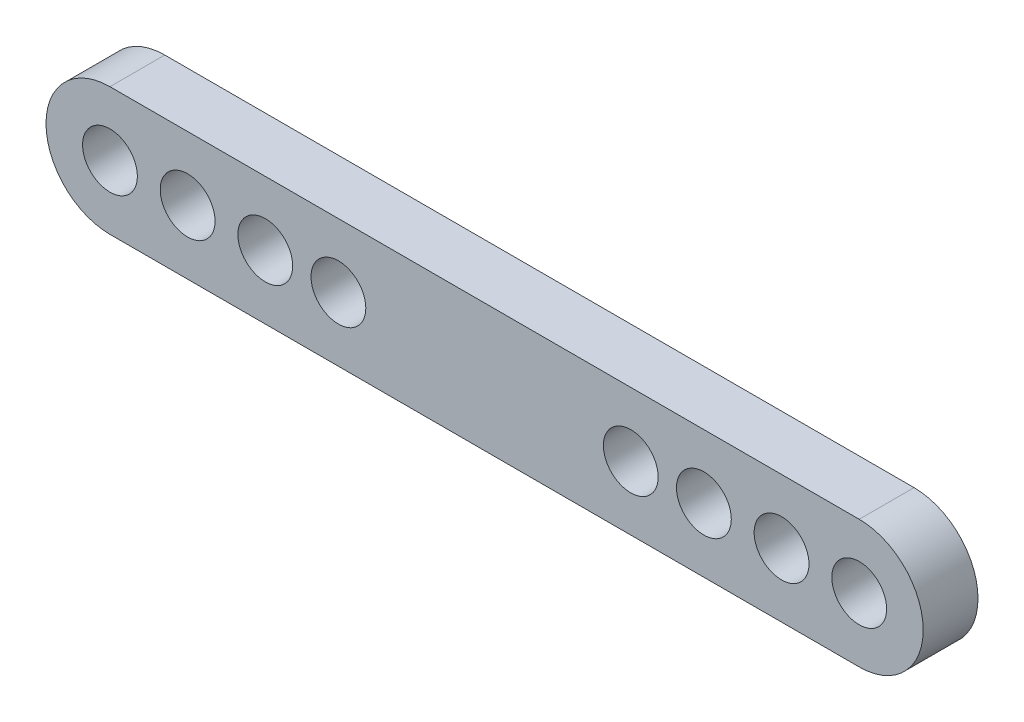
from build123d import *

# Parameters (mm, degrees)
SKETCH_1_R      = 1.5
EXTRUDE_1_DEPTH = 3


with BuildPart() as part:
    # 草图1 → 凸台-拉伸1 (new body)
    with BuildSketch(Plane.XY):
        with BuildLine():
            Line((-20.5, 3.5), (20.5, 3.5))
            ThreePointArc((20.5, 3.5), (24, 0), (20.5, -3.5))
            Line((20.5, -3.5), (-20.5, -3.5))
            ThreePointArc((-20.5, -3.5), (-24, 0), (-20.5, 3.5))
        make_face()
        with Locations((-20.5, 0)):
            Circle(SKETCH_1_R, mode=Mode.SUBTRACT)
        with Locations((-16.25, 0)):
            Circle(SKETCH_1_R, mode=Mode.SUBTRACT)
        with Locations((-12, 0)):
            Circle(SKETCH_1_R, mode=Mode.SUBTRACT)
        with Locations((-8, 0)):
            Circle(SKETCH_1_R, mode=Mode.SUBTRACT)
        with Locations((8, 0)):
            Circle(SKETCH_1_R, mode=Mode.SUBTRACT)
        with Locations((12, 0)):
            Circle(SKETCH_1_R, mode=Mode.SUBTRACT)
        with Locations((16.25, 0)):
            Circle(SKETCH_1_R, mode=Mode.SUBTRACT)
        with Locations((20.5, 0)):
            Circle(SKETCH_1_R, mode=Mode.SUBTRACT)
    extrude(amount=EXTRUDE_1_DEPTH)


solid = part.part
